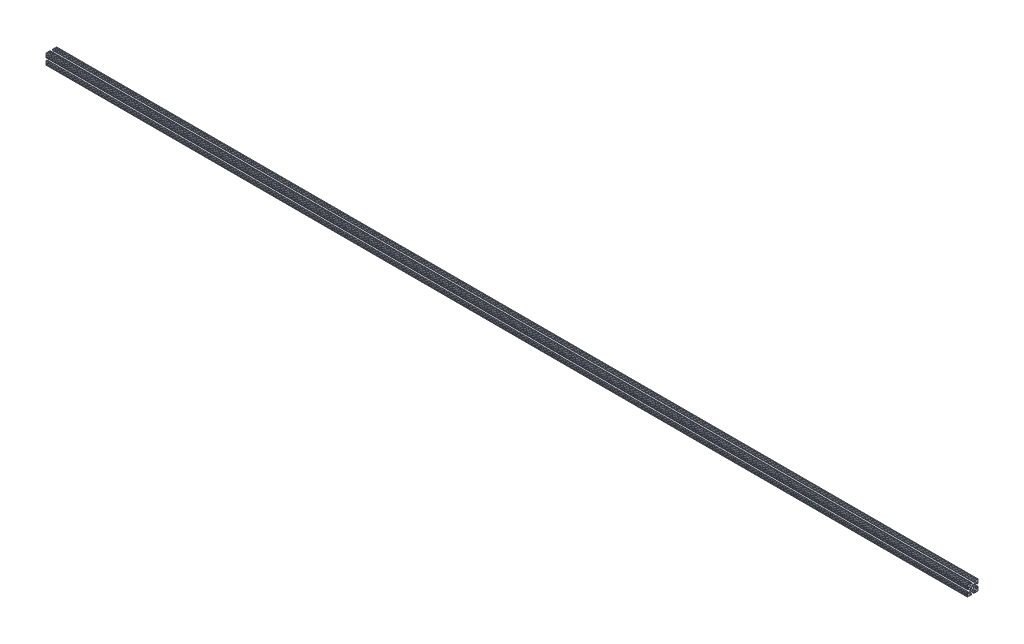
from build123d import *

# Parameters (mm, degrees)
BOSS_EXTRUDE1_DEPTH = 2184.4
SKETCH2_R           = 2.6035
CUT_EXTRUDE1_DEPTH  = 2184.4


with BuildPart() as part:
    # Sketch1 → Boss-Extrude1 (new body)
    with BuildSketch(Plane(origin=(0, 0, 0), x_dir=(0, 0, -1), z_dir=(1, 0, 0))):
        with BuildLine():
            Line((-2.6035, 11.938), (-2.6035, 10.922))
            ThreePointArc((-2.6035, 10.922), (-2.826684633, 10.383184633), (-3.3655, 10.16))
            Line((-3.3655, 10.16), (-5.780369265, 10.16))
            ThreePointArc((-5.780369265, 10.16), (-6.484365469, 9.689604775), (-6.319184633, 8.859184633))
            Line((-6.319184633, 8.859184633), (-2.826684633, 5.366684633))
            ThreePointArc((-2.826684633, 5.366684633), (-2.579474041, 5.201503796), (-2.287869265, 5.1435))
            Line((-2.287869265, 5.1435), (2.287869265, 5.1435))
            ThreePointArc((2.287869265, 5.1435), (2.579474041, 5.201503796), (2.826684633, 5.366684633))
            Line((2.826684633, 5.366684633), (6.319184633, 8.859184633))
            ThreePointArc((6.319184633, 8.859184633), (6.484365469, 9.689604775), (5.780369265, 10.16))
            Line((5.780369265, 10.16), (3.3655, 10.16))
            ThreePointArc((3.3655, 10.16), (2.826684633, 10.383184633), (2.6035, 10.922))
            Line((2.6035, 10.922), (2.6035, 11.938))
            ThreePointArc((2.6035, 11.938), (2.826684633, 12.476815367), (3.3655, 12.7))
            Line((3.3655, 12.7), (5.2917598, 12.7))
            ThreePointArc((5.2917598, 12.7), (5.9267598, 12.065), (6.5617598, 12.7))
            Line((6.5617598, 12.7), (8.6783418, 12.7))
            ThreePointArc((8.6783418, 12.7), (9.3133418, 12.065), (9.9483418, 12.7))
            Line((9.9483418, 12.7), (11.938, 12.7))
            ThreePointArc((11.938, 12.7), (12.476815367, 12.476815367), (12.7, 11.938))
            Line((12.7, 11.938), (12.7, 9.9483418))
            ThreePointArc((12.7, 9.9483418), (12.065, 9.3133418), (12.7, 8.6783418))
            Line((12.7, 8.6783418), (12.7, 6.5616836))
            ThreePointArc((12.7, 6.5616836), (12.065, 5.9266836), (12.7, 5.2916836))
            Line((12.7, 5.2916836), (12.7, 3.3655))
            ThreePointArc((12.7, 3.3655), (12.476815367, 2.826684633), (11.938, 2.6035))
            Line((11.938, 2.6035), (10.922, 2.6035))
            ThreePointArc((10.922, 2.6035), (10.383184633, 2.826684633), (10.16, 3.3655))
            Line((10.16, 3.3655), (10.16, 5.780369265))
            ThreePointArc((10.16, 5.780369265), (9.689604775, 6.484365469), (8.859184633, 6.319184633))
            Line((8.859184633, 6.319184633), (5.366684633, 2.826684633))
            ThreePointArc((5.366684633, 2.826684633), (5.201503796, 2.579474041), (5.1435, 2.287869265))
            Line((5.1435, 2.287869265), (5.1435, -2.287869265))
            ThreePointArc((5.1435, -2.287869265), (5.201503796, -2.579474041), (5.366684633, -2.826684633))
            Line((5.366684633, -2.826684633), (8.859184633, -6.319184633))
            ThreePointArc((8.859184633, -6.319184633), (9.689604775, -6.484365469), (10.16, -5.780369265))
            Line((10.16, -5.780369265), (10.16, -3.3655))
            ThreePointArc((10.16, -3.3655), (10.383184633, -2.826684633), (10.922, -2.6035))
            Line((10.922, -2.6035), (11.938, -2.6035))
            ThreePointArc((11.938, -2.6035), (12.476815367, -2.826684633), (12.7, -3.3655))
            Line((12.7, -3.3655), (12.7, -5.2917598))
            ThreePointArc((12.7, -5.2917598), (12.065, -5.9267598), (12.7, -6.5617598))
            Line((12.7, -6.5617598), (12.7, -8.6783418))
            ThreePointArc((12.7, -8.6783418), (12.065, -9.3133418), (12.7, -9.9483418))
            Line((12.7, -9.9483418), (12.7, -11.938))
            ThreePointArc((12.7, -11.938), (12.476815367, -12.476815367), (11.938, -12.7))
            Line((11.938, -12.7), (9.9483418, -12.7))
            ThreePointArc((9.9483418, -12.7), (9.3133418, -12.065), (8.6783418, -12.7))
            Line((8.6783418, -12.7), (6.5616836, -12.7))
            ThreePointArc((6.5616836, -12.7), (5.9266836, -12.065), (5.2916836, -12.7))
            Line((5.2916836, -12.7), (3.3655, -12.7))
            ThreePointArc((3.3655, -12.7), (2.826684633, -12.476815367), (2.6035, -11.938))
            Line((2.6035, -11.938), (2.6035, -10.922))
            ThreePointArc((2.6035, -10.922), (2.826684633, -10.383184633), (3.3655, -10.16))
            Line((3.3655, -10.16), (5.780369265, -10.16))
            ThreePointArc((5.780369265, -10.16), (6.484365469, -9.689604775), (6.319184633, -8.859184633))
            Line((6.319184633, -8.859184633), (2.826684633, -5.366684633))
            ThreePointArc((2.826684633, -5.366684633), (2.579474041, -5.201503796), (2.287869265, -5.1435))
            Line((2.287869265, -5.1435), (-2.287869265, -5.1435))
            ThreePointArc((-2.287869265, -5.1435), (-2.579474041, -5.201503796), (-2.826684633, -5.366684633))
            Line((-2.826684633, -5.366684633), (-6.319184633, -8.859184633))
            ThreePointArc((-6.319184633, -8.859184633), (-6.484365469, -9.689604775), (-5.780369265, -10.16))
            Line((-5.780369265, -10.16), (-3.3655, -10.16))
            ThreePointArc((-3.3655, -10.16), (-2.826684633, -10.383184633), (-2.6035, -10.922))
            Line((-2.6035, -10.922), (-2.6035, -11.938))
            ThreePointArc((-2.6035, -11.938), (-2.826684633, -12.476815367), (-3.3655, -12.7))
            Line((-3.3655, -12.7), (-5.2917598, -12.7))
            ThreePointArc((-5.2917598, -12.7), (-5.9267598, -12.065), (-6.5617598, -12.7))
            Line((-6.5617598, -12.7), (-8.6783418, -12.7))
            ThreePointArc((-8.6783418, -12.7), (-9.3133418, -12.065), (-9.9483418, -12.7))
            Line((-9.9483418, -12.7), (-11.938, -12.7))
            ThreePointArc((-11.938, -12.7), (-12.476815367, -12.476815367), (-12.7, -11.938))
            Line((-12.7, -11.938), (-12.7, -9.9483418))
            ThreePointArc((-12.7, -9.9483418), (-12.065, -9.3133418), (-12.7, -8.6783418))
            Line((-12.7, -8.6783418), (-12.7, -6.5616836))
            ThreePointArc((-12.7, -6.5616836), (-12.065, -5.9266836), (-12.7, -5.2916836))
            Line((-12.7, -5.2916836), (-12.7, -3.3655))
            ThreePointArc((-12.7, -3.3655), (-12.476815367, -2.826684633), (-11.938, -2.6035))
            Line((-11.938, -2.6035), (-10.922, -2.6035))
            ThreePointArc((-10.922, -2.6035), (-10.383184633, -2.826684633), (-10.16, -3.3655))
            Line((-10.16, -3.3655), (-10.16, -5.780369265))
            ThreePointArc((-10.16, -5.780369265), (-9.689604775, -6.484365469), (-8.859184633, -6.319184633))
            Line((-8.859184633, -6.319184633), (-5.366684633, -2.826684633))
            ThreePointArc((-5.366684633, -2.826684633), (-5.201503796, -2.579474041), (-5.1435, -2.287869265))
            Line((-5.1435, -2.287869265), (-5.1435, 2.287869265))
            ThreePointArc((-5.1435, 2.287869265), (-5.201503796, 2.579474041), (-5.366684633, 2.826684633))
            Line((-5.366684633, 2.826684633), (-8.859184633, 6.319184633))
            ThreePointArc((-8.859184633, 6.319184633), (-9.689604775, 6.484365469), (-10.16, 5.780369265))
            Line((-10.16, 5.780369265), (-10.16, 3.3655))
            ThreePointArc((-10.16, 3.3655), (-10.383184633, 2.826684633), (-10.922, 2.6035))
            Line((-10.922, 2.6035), (-11.938, 2.6035))
            ThreePointArc((-11.938, 2.6035), (-12.476815367, 2.826684633), (-12.7, 3.3655))
            Line((-12.7, 3.3655), (-12.7, 5.2917598))
            ThreePointArc((-12.7, 5.2917598), (-12.065, 5.9267598), (-12.7, 6.5617598))
            Line((-12.7, 6.5617598), (-12.7, 8.6783418))
            ThreePointArc((-12.7, 8.6783418), (-12.065, 9.3133418), (-12.7, 9.9483418))
            Line((-12.7, 9.9483418), (-12.7, 11.938))
            ThreePointArc((-12.7, 11.938), (-12.476815367, 12.476815367), (-11.938, 12.7))
            Line((-11.938, 12.7), (-9.9483418, 12.7))
            ThreePointArc((-9.9483418, 12.7), (-9.3133418, 12.065), (-8.6783418, 12.7))
            Line((-8.6783418, 12.7), (-6.5616836, 12.7))
            ThreePointArc((-6.5616836, 12.7), (-5.9266836, 12.065), (-5.2916836, 12.7))
            Line((-5.2916836, 12.7), (-3.3655, 12.7))
            ThreePointArc((-3.3655, 12.7), (-2.826684633, 12.476815367), (-2.6035, 11.938))
        make_face()
    extrude(amount=BOSS_EXTRUDE1_DEPTH)

    # Sketch2 → Cut-Extrude1 (cut)
    with BuildSketch(Plane.ZY):
        Circle(SKETCH2_R)
    extrude(amount=-CUT_EXTRUDE1_DEPTH, mode=Mode.SUBTRACT)


solid = part.part
